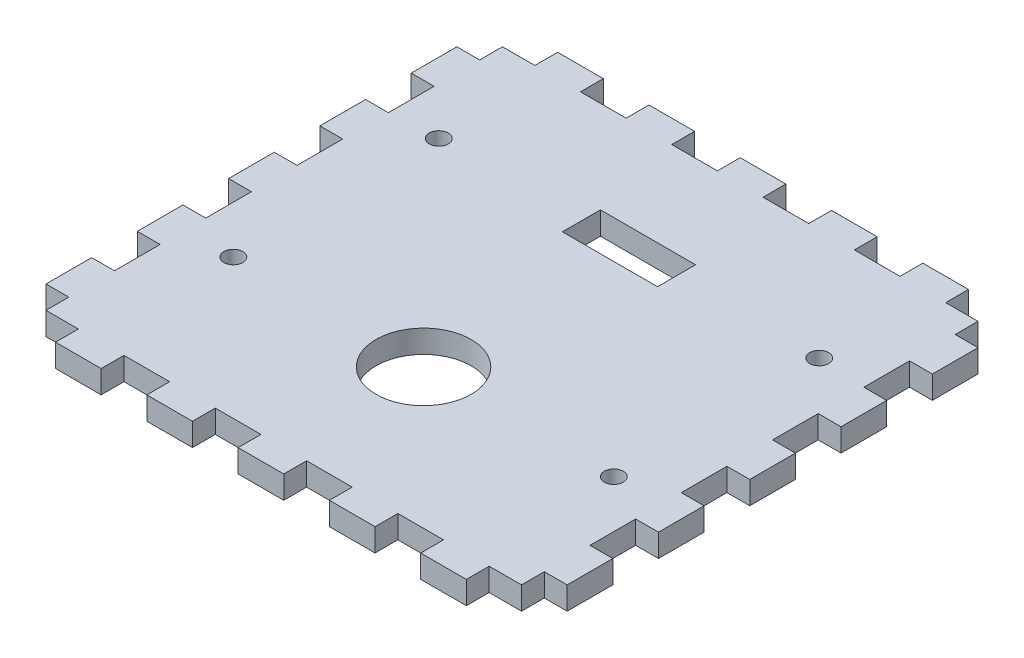
from build123d import *

# Parameters (mm, degrees)
BOSS_EXTRUDE2_DEPTH = 6
SKETCH2_R           = 2.5
SKETCH2_R_2         = 12.5
SKETCH2_W           = 25
SKETCH2_H           = 10
CUT_EXTRUDE2_DEPTH  = 6


with BuildPart() as part:
    # Sketch1 → Boss-Extrude2 (new body)
    with BuildSketch(Plane(origin=(0, 0, 0), x_dir=(1, 0, 0), z_dir=(0, 1, 0))):
        Polygon((-62.5, -60), (-54, -60), (-54, -66), (-42, -66), (-42, -60), (-30, -60), (-30, -66), (-18, -66), (-18, -60), (-6, -60), (-6, -66), (6, -66), (6, -60), (18, -60), (18, -66), (30, -66), (30, -60), (42, -60), (42, -66), (54, -66), (54, -60), (62.5, -60), (62.5, -54), (68.5, -54), (68.5, -42), (62.5, -42), (62.5, -30), (68.5, -30), (68.5, -18), (62.5, -18), (62.5, -6), (68.5, -6), (68.5, 6), (62.5, 6), (62.5, 18), (68.5, 18), (68.5, 30), (62.5, 30), (62.5, 42), (68.5, 42), (68.5, 54), (62.5, 54), (62.5, 60), (54, 60), (54, 66), (42, 66), (42, 60), (30, 60), (30, 66), (18, 66), (18, 60), (6, 60), (6, 66), (-6, 66), (-6, 60), (-18, 60), (-18, 66), (-30, 66), (-30, 60), (-42, 60), (-42, 66), (-54, 66), (-54, 60), (-62.5, 60), (-62.5, 54), (-68.5, 54), (-68.5, 42), (-62.5, 42), (-62.5, 30), (-68.5, 30), (-68.5, 18), (-62.5, 18), (-62.5, 6), (-68.5, 6), (-68.5, -6), (-62.5, -6), (-62.5, -18), (-68.5, -18), (-68.5, -30), (-62.5, -30), (-62.5, -42), (-68.5, -42), (-68.5, -54), (-62.5, -54), align=None)
    extrude(amount=BOSS_EXTRUDE2_DEPTH)

    # Sketch2 → Cut-Extrude2 (cut)
    with BuildSketch(Plane(origin=(0, 6, 0), x_dir=(1, 0, 0), z_dir=(0, 1, 0))):
        with Locations((-50, -23.25)):
            Circle(SKETCH2_R)
        with Locations((0, -23.25)):
            Circle(SKETCH2_R_2)
        with Locations((50, -23.25)):
            Circle(SKETCH2_R)
        with Locations((-50, 30.75)):
            Circle(SKETCH2_R)
        with Locations((0, 30.75)):
            Rectangle(SKETCH2_W, SKETCH2_H)
        with Locations((50, 30.75)):
            Circle(SKETCH2_R)
    extrude(amount=-CUT_EXTRUDE2_DEPTH, mode=Mode.SUBTRACT)


solid = part.part
